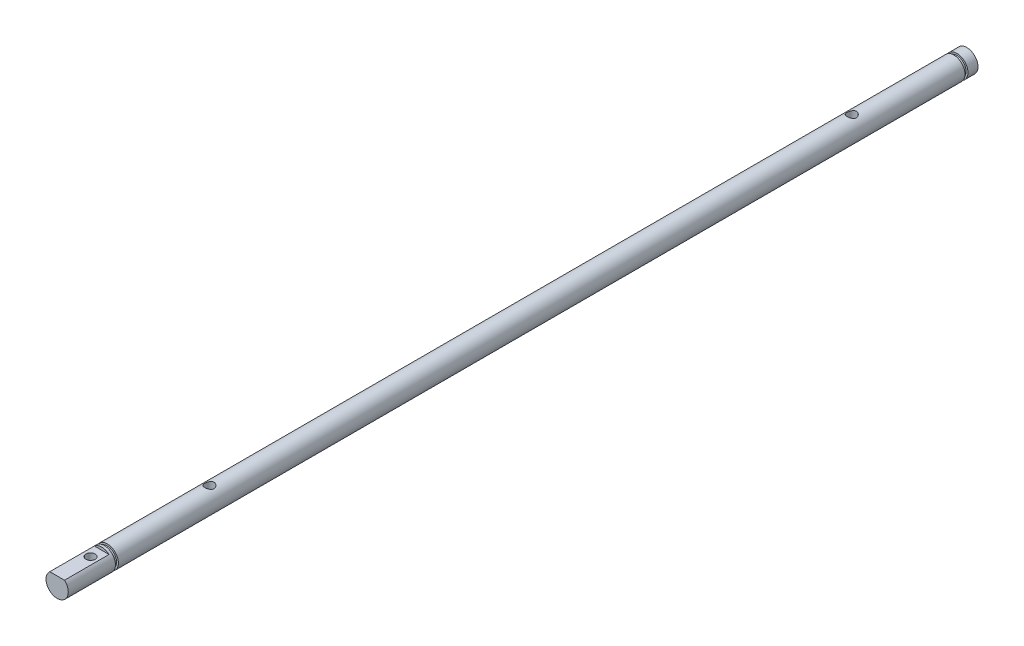
from build123d import *

# Parameters (mm, degrees)
SKETCH1_R           = 3
BOSS_EXTRUDE1_DEPTH = 245
CUT_EXTRUDE2_DEPTH  = 12
M3_TAPPED_HOLE6_D   = 2.5
SKETCH24_W          = 0.8
SKETCH24_H          = 0.5
M3_TAPPED_HOLE7_D   = 2.5
SKETCH28_W          = 0.5
SKETCH28_H          = 0.8


with BuildPart() as part:
    # Sketch1 → Boss-Extrude1 (new body)
    with BuildSketch(Plane.XY):
        Circle(SKETCH1_R)
    extrude(amount=BOSS_EXTRUDE1_DEPTH)

    # Sketch21 → Cut-Extrude2 (cut)
    with BuildSketch(Plane.XY.offset(245)):
        with BuildLine():
            Line((-1.984313483, 2.25), (1.984313483, 2.25))
            ThreePointArc((1.984313483, 2.25), (0, 3), (-1.984313483, 2.25))
        make_face()
    extrude(amount=-CUT_EXTRUDE2_DEPTH, mode=Mode.SUBTRACT)

    # M3 Tapped Hole6 (through all)
    with Locations(Plane(origin=(0, 2.25, 236), x_dir=(0, 0, 1), z_dir=(0, 1, 0))):
        with Locations((0, 0)):
            Hole(M3_TAPPED_HOLE6_D / 2)

    # Sketch24 → Cut-Revolve1 (revolve, cut)
    with BuildSketch(Plane(origin=(0, 0, 0), x_dir=(0, 0, -1), z_dir=(1, 0, 0))):
        with Locations((-231.9, 2.75)):
            Rectangle(SKETCH24_W, SKETCH24_H)
    revolve(axis=Axis((0, 0, 245), (0, 0, -1)), mode=Mode.SUBTRACT)

    # M3 Tapped Hole7 (through all)
    with Locations(Plane(origin=(0, 3.25, 204), x_dir=(0, 0, 1), z_dir=(0, 1, 0))):
        with Locations((0, 0), (-173, 0)):
            Hole(M3_TAPPED_HOLE7_D / 2)

    # Sketch28 → Cut-Revolve2 (revolve, cut)
    with BuildSketch(Plane(origin=(0, 0, 0), x_dir=(1, 0, 0), z_dir=(0, 1, 0))):
        with Locations((2.75, -3.1)):
            Rectangle(SKETCH28_W, SKETCH28_H)
    revolve(axis=Axis((0, 0, 245), (0, 0, -1)), mode=Mode.SUBTRACT)


solid = part.part
